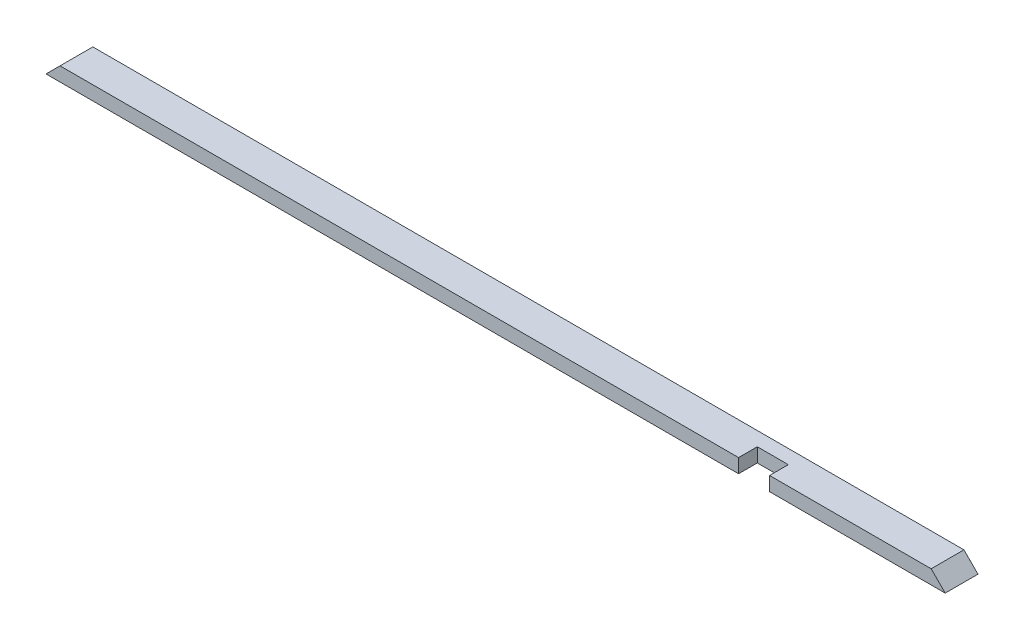
from build123d import *

# Parameters (mm, degrees)
SKETCH1_W           = 2438.4
SKETCH1_H           = 88.9
BOSS_EXTRUDE1_DEPTH = 38.1
CUT_EXTRUDE1_DEPTH  = 89.9
SKETCH3_W           = 84.1375
SKETCH3_H           = 50.8
CUT_EXTRUDE2_DEPTH  = 39.1


with BuildPart() as part:
    # Sketch1 → Boss-Extrude1 (new body)
    with BuildSketch(Plane(origin=(0, 0, 0), x_dir=(1, 0, 0), z_dir=(0, 1, 0))):
        with Locations((1219.2, 44.45)):
            Rectangle(SKETCH1_W, SKETCH1_H)
    extrude(amount=BOSS_EXTRUDE1_DEPTH)

    # Sketch2 → Cut-Extrude1 (cut, through all)
    with BuildSketch(Plane.XY):
        Polygon((0, 0), (38.1, 38.1), (0, 38.1), align=None)
        Polygon((2438.4, 0), (2438.4, 38.1), (2400.3, 38.1), align=None)
    extrude(amount=-CUT_EXTRUDE1_DEPTH, mode=Mode.SUBTRACT)

    # Sketch3 → Cut-Extrude2 (cut, through all)
    with BuildSketch(Plane(origin=(0, 38.1, 0), x_dir=(1, 0, 0), z_dir=(0, 1, 0))):
        with Locations((1920.08125, 25.4)):
            Rectangle(SKETCH3_W, SKETCH3_H)
    extrude(amount=-CUT_EXTRUDE2_DEPTH, mode=Mode.SUBTRACT)


solid = part.part
